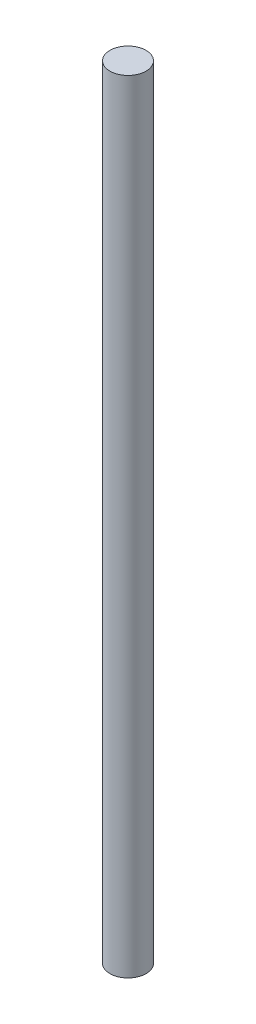
from build123d import *

# Parameters (mm, degrees)
SKETCH1_R           = 3
BOSS_EXTRUDE1_DEPTH = 130


with BuildPart() as part:
    # Sketch1 → Boss-Extrude1 (new body)
    with BuildSketch(Plane(origin=(0, 0, 0), x_dir=(1, 0, 0), z_dir=(0, 1, 0))):
        Circle(SKETCH1_R)
    extrude(amount=BOSS_EXTRUDE1_DEPTH)


solid = part.part
